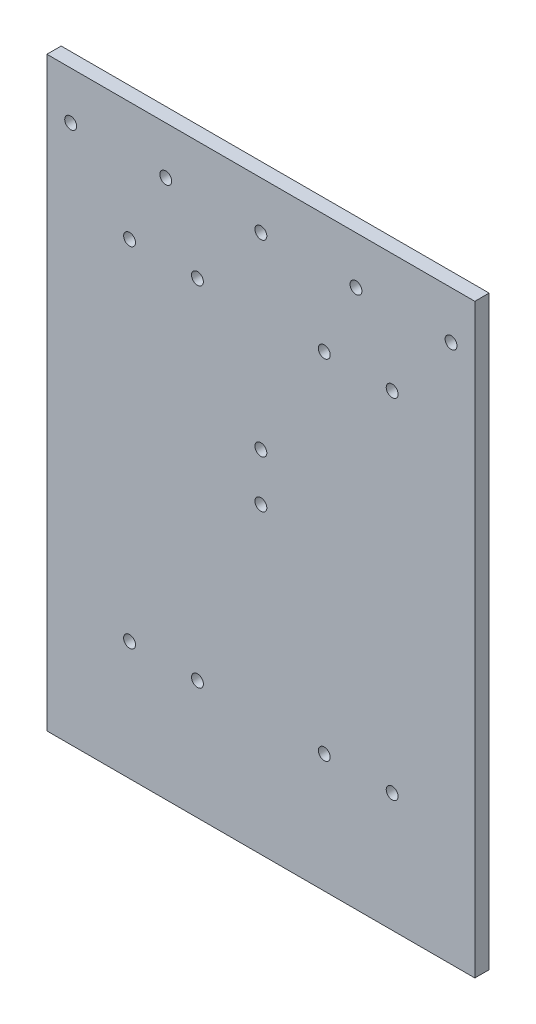
from build123d import *

# Parameters (mm, degrees)
SKETCH1_W           = 180
SKETCH1_H           = 246.5
SKETCH1_R           = 2.5
BOSS_EXTRUDE1_DEPTH = 6


with BuildPart() as part:
    # Sketch1 → Boss-Extrude1 (new body)
    with BuildSketch(Plane.XY):
        with Locations((0, -73.25)):
            Rectangle(SKETCH1_W, SKETCH1_H)
        with Locations((-55.225, 0)):
            Circle(SKETCH1_R, mode=Mode.SUBTRACT)
        with Locations((-26.675, 0)):
            Circle(SKETCH1_R, mode=Mode.SUBTRACT)
        with Locations((55.225, 0)):
            Circle(SKETCH1_R, mode=Mode.SUBTRACT)
        with Locations((26.675, 0)):
            Circle(SKETCH1_R, mode=Mode.SUBTRACT)
        with Locations((-55.225, -146.5)):
            Circle(SKETCH1_R, mode=Mode.SUBTRACT)
        with Locations((-26.675, -146.5)):
            Circle(SKETCH1_R, mode=Mode.SUBTRACT)
        with Locations((55.225, -146.5)):
            Circle(SKETCH1_R, mode=Mode.SUBTRACT)
        with Locations((26.675, -146.5)):
            Circle(SKETCH1_R, mode=Mode.SUBTRACT)
        with Locations((-80, 30)):
            Circle(SKETCH1_R, mode=Mode.SUBTRACT)
        with Locations((-40, 30)):
            Circle(SKETCH1_R, mode=Mode.SUBTRACT)
        with Locations((80, 30)):
            Circle(SKETCH1_R, mode=Mode.SUBTRACT)
        with Locations((40, 30)):
            Circle(SKETCH1_R, mode=Mode.SUBTRACT)
        with Locations((0, 30)):
            Circle(SKETCH1_R, mode=Mode.SUBTRACT)
        with Locations((0, -49)):
            Circle(SKETCH1_R, mode=Mode.SUBTRACT)
        with Locations((0, -69)):
            Circle(SKETCH1_R, mode=Mode.SUBTRACT)
    extrude(amount=BOSS_EXTRUDE1_DEPTH)


solid = part.part
